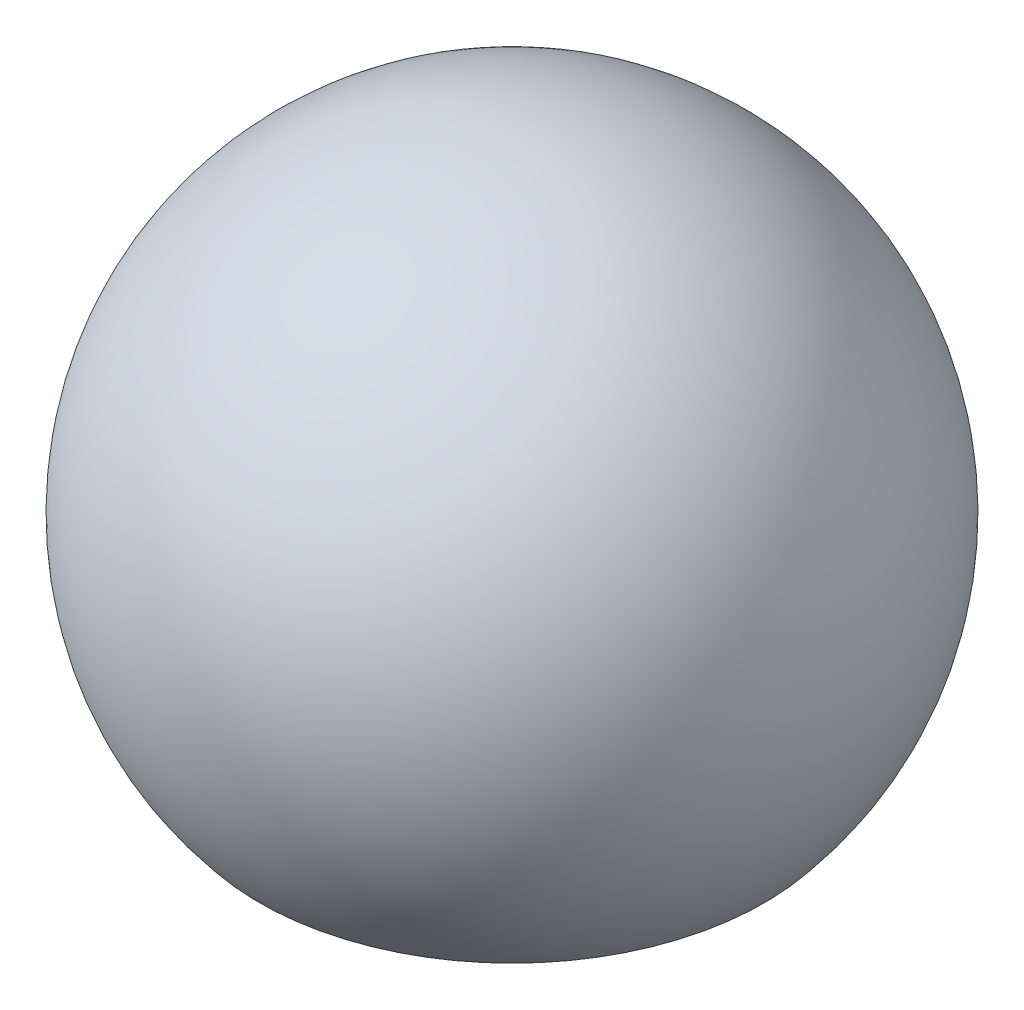
from build123d import *


with BuildPart() as part:
    # Sketch2 one side → Reachable workspace (revolve)
    with BuildSketch(Plane.XY):
        with BuildLine():
            Line((-1225.67110899, -528.460175498), (-459.626665871, 114.327434188))
            ThreePointArc((-459.626665871, 114.327434188), (-543.784672222, 753.570957044), (0, 1100))
            Line((0, 1100), (0, 2100))
            ThreePointArc((0, 2100), (-1450.092459259, 1176.189218785), (-1225.67110899, -528.460175498))
        make_face()
    revolve(axis=Axis((0, -528.460175498, 0), (0, 1, 0)))


solid = part.part
